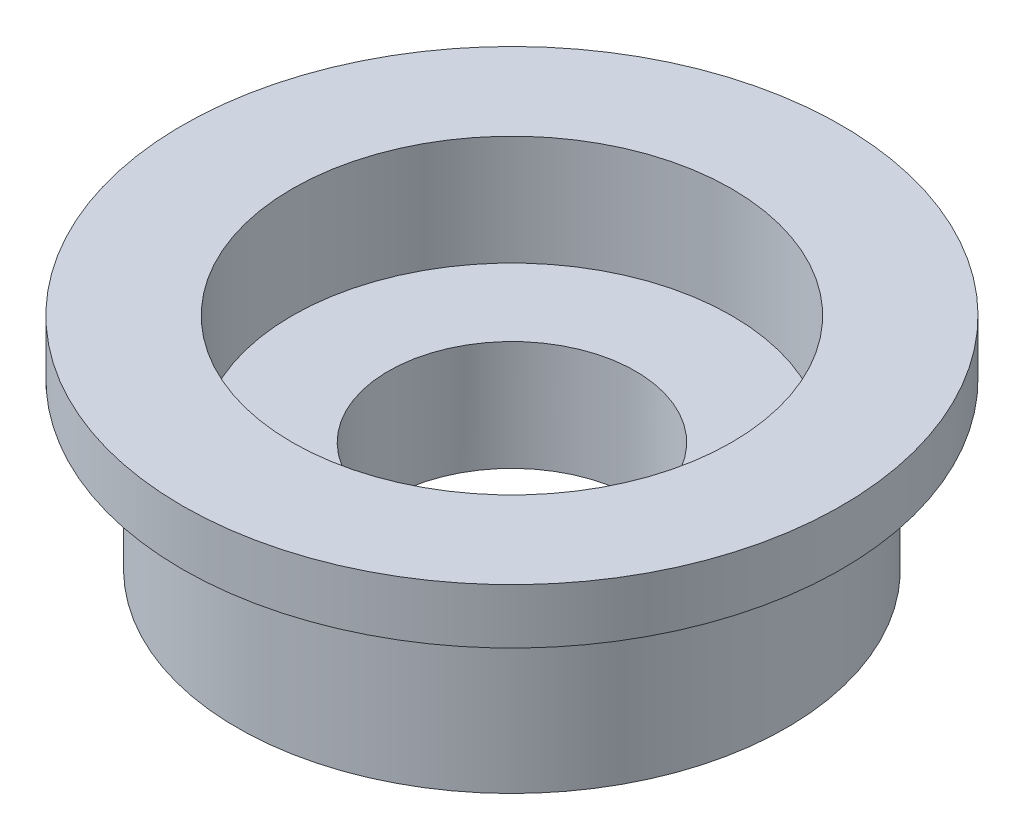
from build123d import *

# Parameters (mm, degrees)
SKETCH_1_R          = 6
EXTRUDE_1_DEPTH     = 1
SKETCH_2_R          = 5
EXTRUDE_2_DEPTH     = 3
SKETCH_3_R          = 4
CUT_EXTRUDE_1_DEPTH = 2
SKETCH_4_R          = 2.25
CUT_EXTRUDE_2_DEPTH = 10


with BuildPart() as part:
    # 草图1 → 凸台-拉伸1 (new body)
    with BuildSketch(Plane(origin=(0, 0, 0), x_dir=(1, 0, 0), z_dir=(0, 1, 0))):
        Circle(SKETCH_1_R)
    extrude(amount=EXTRUDE_1_DEPTH)

    # 草图2 → 凸台-拉伸2 (add)
    with BuildSketch(Plane.XZ):
        Circle(SKETCH_2_R)
    extrude(amount=EXTRUDE_2_DEPTH)

    # 草图3 → 切除-拉伸1 (cut)
    with BuildSketch(Plane(origin=(0, 1, 0), x_dir=(1, 0, 0), z_dir=(0, 1, 0))):
        Circle(SKETCH_3_R)
    extrude(amount=-CUT_EXTRUDE_1_DEPTH, mode=Mode.SUBTRACT)

    # 草图4 → 切除-拉伸2 (cut)
    with BuildSketch(Plane(origin=(0, -1, 0), x_dir=(1, 0, 0), z_dir=(0, 1, 0))):
        Circle(SKETCH_4_R)
    extrude(amount=-CUT_EXTRUDE_2_DEPTH, mode=Mode.SUBTRACT)


solid = part.part
